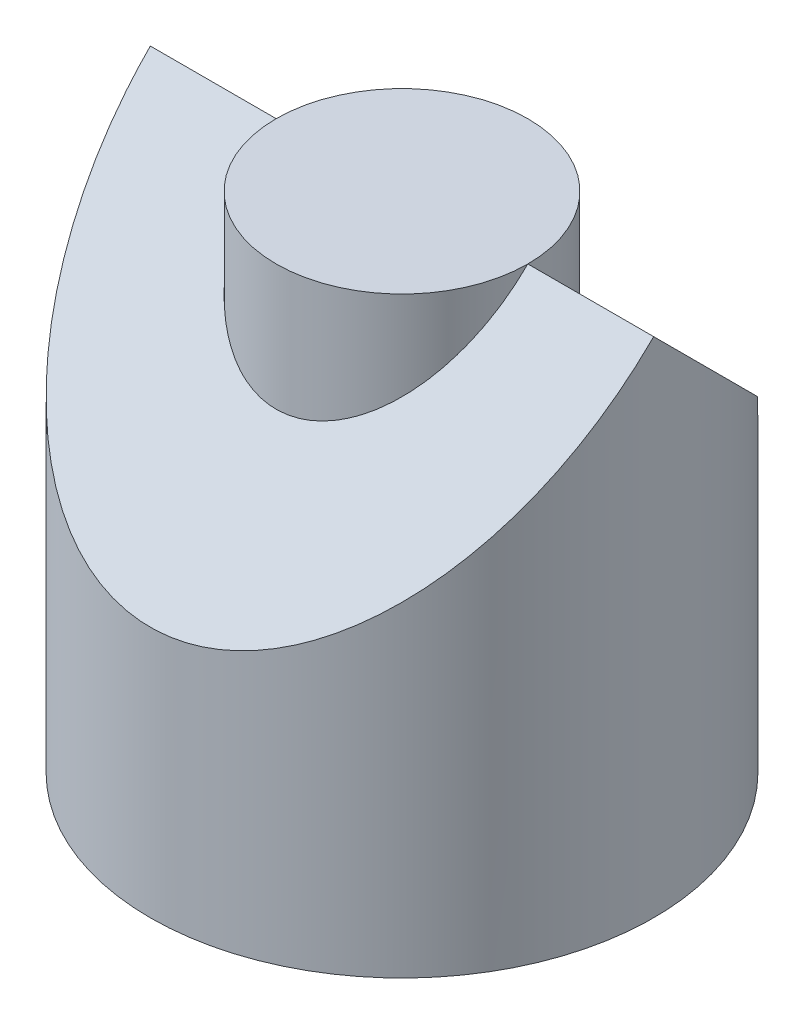
from build123d import *

# Parameters (mm, degrees)
SKETCH1_R           = 2
SKETCH1_R_2         = 1
BOSS_EXTRUDE1_DEPTH = 4
CUT_EXTRUDE1_DEPTH  = 2
SKETCH3_R           = 1
BOSS_EXTRUDE2_DEPTH = 4


with BuildPart() as part:
    # Sketch1 → Boss-Extrude1 (new body)
    with BuildSketch(Plane(origin=(0, 0, 0), x_dir=(1, 0, 0), z_dir=(0, 1, 0))):
        Circle(SKETCH1_R)
        Circle(SKETCH1_R_2, mode=Mode.SUBTRACT)
    extrude(amount=BOSS_EXTRUDE1_DEPTH)

    # Sketch2 → Cut-Extrude1 (cut, symmetric)
    with BuildSketch(Plane(origin=(0, 0, 0), x_dir=(0, 0, -1), z_dir=(1, 0, 0))):
        Polygon((2, 4), (0, 4), (2, 2), align=None)
        Polygon((-2, 4), (-2, 2), (0, 4), align=None)
    extrude(amount=CUT_EXTRUDE1_DEPTH, both=True, mode=Mode.SUBTRACT)


with BuildPart() as body_2:
    # Sketch3 → Boss-Extrude2 (new body)
    with BuildSketch(Plane.XZ):
        Circle(SKETCH3_R)
    extrude(amount=-BOSS_EXTRUDE2_DEPTH)


solid = Compound([part.part, body_2.part])
